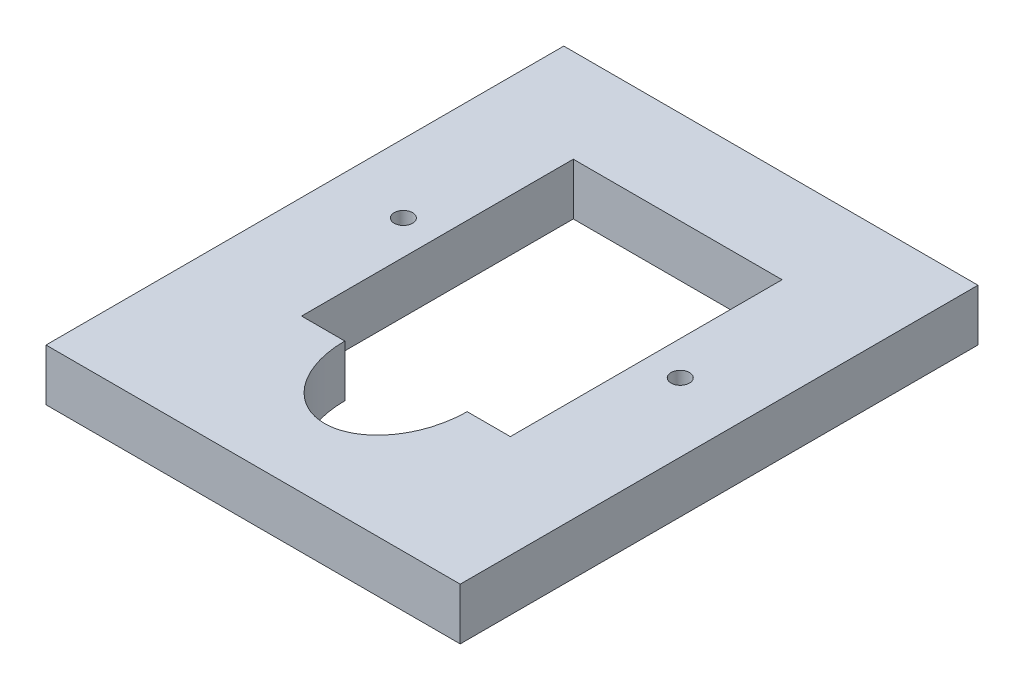
from build123d import *

# Parameters (mm, degrees)
SKETCH1_W           = 50.8
SKETCH1_H           = 63.5
SKETCH1_R           = 1.1303
BOSS_EXTRUDE1_DEPTH = 6.35


with BuildPart() as part:
    # Sketch1 → Boss-Extrude1 (new body)
    with BuildSketch(Plane(origin=(0, 0, 0), x_dir=(1, 0, 0), z_dir=(0, 1, 0))):
        with Locations((21.766538168, -1.869249963)):
            Rectangle(SKETCH1_W, SKETCH1_H)
        with Locations((38.743898168, 1.788350037)):
            Circle(SKETCH1_R, mode=Mode.SUBTRACT)
        with Locations((4.789178168, 1.788350037)):
            Circle(SKETCH1_R, mode=Mode.SUBTRACT)
        with BuildLine():
            Line((29.266538168, -14.874049963), (34.568138168, -14.874049963))
            Line((34.568138168, -14.874049963), (34.568138168, 18.450750037))
            Line((34.568138168, 18.450750037), (8.964938168, 18.450750037))
            Line((8.964938168, 18.450750037), (8.964938168, -14.874049963))
            Line((8.964938168, -14.874049963), (14.266538168, -14.874049963))
            add(Edge.make_bspline(
                [(14.266538168, -14.874049963), (14.266538168, -24.874049963), (21.766538168, -24.874049963), (29.266538168, -24.874049963), (29.266538168, -14.874049963)],
                knots=[1.570796327, 1.570796327, 1.570796327, 3.141592654, 3.141592654, 4.71238898, 4.71238898, 4.71238898], degree=2, weights=[1, 0.707106781, 1, 0.707106781, 1]))
        make_face(mode=Mode.SUBTRACT)
    extrude(amount=BOSS_EXTRUDE1_DEPTH)


solid = part.part
